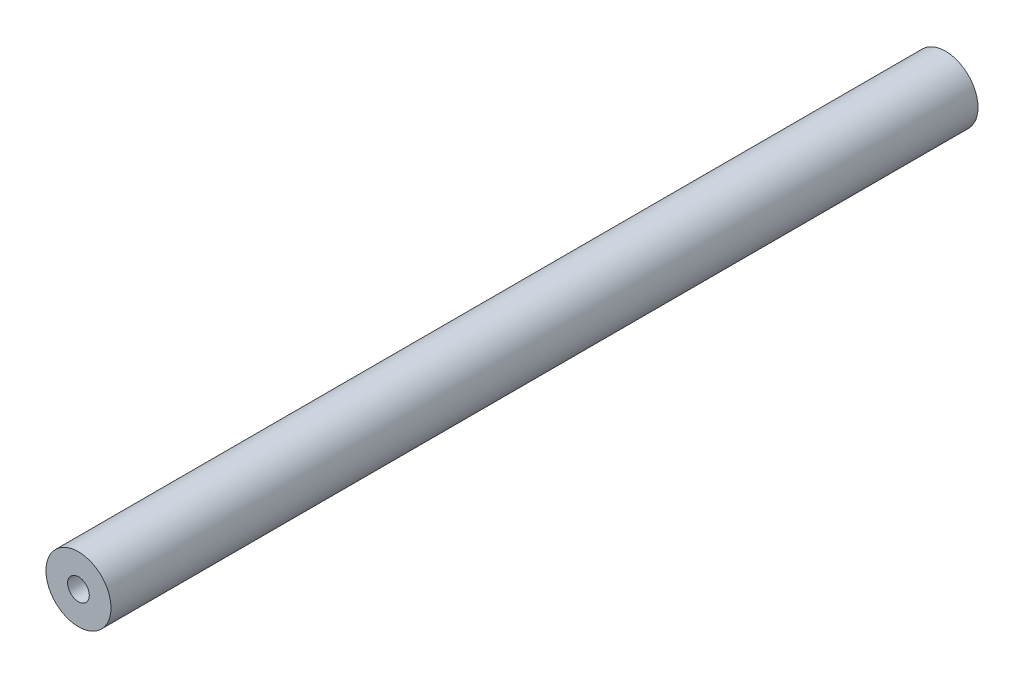
from build123d import *

# Parameters (mm, degrees)
CROQUIS1_R              = 37.5
CROQUIS1_R_2            = 12.5
SALIENTE_EXTRUIR1_DEPTH = 1000


with BuildPart() as part:
    # Croquis1 → Saliente-Extruir1 (new body)
    with BuildSketch(Plane.XY):
        Circle(CROQUIS1_R)
        Circle(CROQUIS1_R_2, mode=Mode.SUBTRACT)
    extrude(amount=SALIENTE_EXTRUIR1_DEPTH)


solid = part.part
